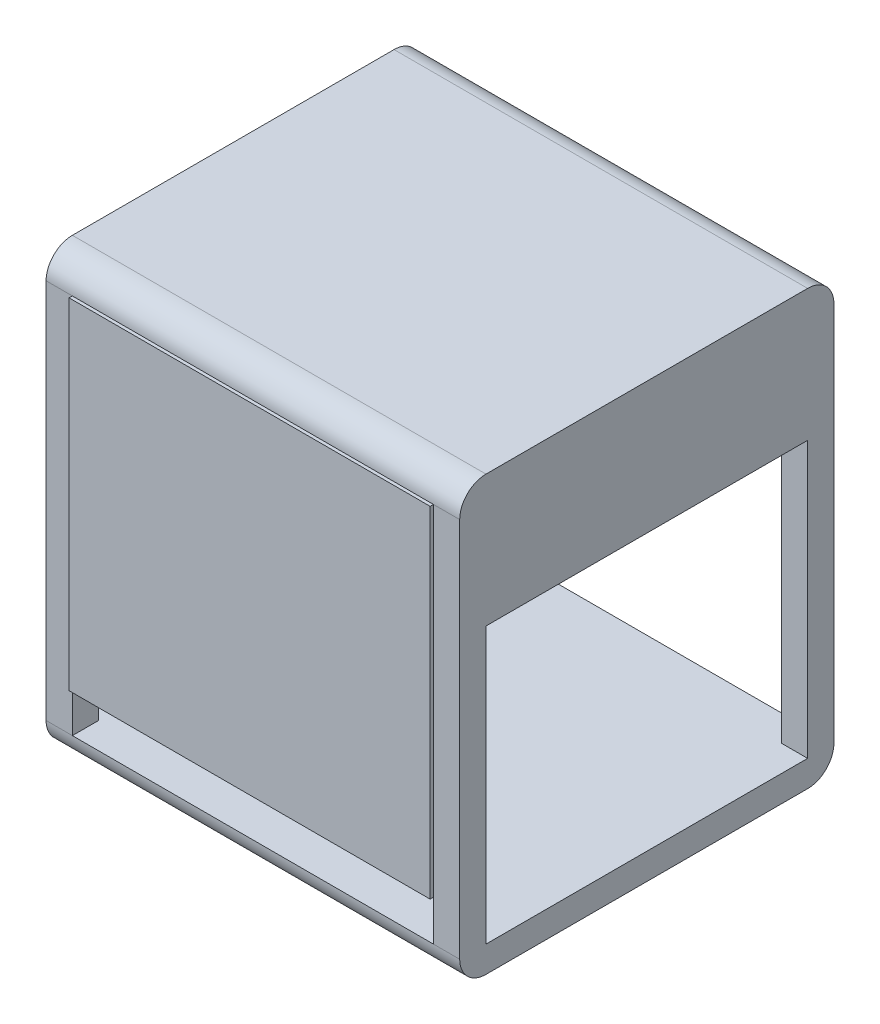
from build123d import *

# Parameters (mm, degrees)
SKETCH1_W                = 630
SKETCH1_H                = 570
BOSS_EXTRUDE1_DEPTH      = 660
FILLET1_R                = 40
CUT_EXTRUDE1_DEPTH       = 660
CUT_EXTRUDE1_DEPTH_BACK  = 5000
SKETCH3_W                = 550
SKETCH3_H                = 580
CUT_EXTRUDE2_DEPTH       = 5000
CUT_EXTRUDE2_DEPTH_BACK  = 5000
SKETCH4_W                = 490
SKETCH4_H                = 419.595995266
SKETCH5_W                = 601.346764223
SKETCH5_H                = 47.577370451
BOSS_EXTRUDE2_DEPTH      = 100
BOSS_EXTRUDE3_DEPTH      = 50
BOSS_EXTRUDE3_DEPTH_BACK = 10
SKETCH6_W                = 78.570394343
SKETCH6_H                = 303.095065724
SKETCH7_R                = 11.248698276
BOSS_EXTRUDE4_DEPTH      = 50
BOSS_EXTRUDE4_TAPER      = 8
SKETCH8_W                = 550
SKETCH8_H                = 518.195144688
BOSS_EXTRUDE5_DEPTH      = 5


with BuildPart() as part:
    # Sketch1 → Boss-Extrude1 (new body)
    with BuildSketch(Plane(origin=(0, 0, 0), x_dir=(1, 0, 0), z_dir=(0, 1, 0))):
        with Locations((315, 285)):
            Rectangle(SKETCH1_W, SKETCH1_H)
    extrude(amount=BOSS_EXTRUDE1_DEPTH)

    # Fillet1
    fillet1_edges = [part.edges().sort_by_distance(p)[0] for p in [
        (315, 0, -570),
        (315, 660, -570),
        (315, 0, 0),
        (315, 660, 0),
    ]]
    fillet(fillet1_edges, radius=FILLET1_R)

    # Sketch3 → Cut-Extrude1 (cut, two sides: drawn at the far end of the back side and taken through both)
    with BuildSketch(Plane.XY.offset(-CUT_EXTRUDE1_DEPTH_BACK)):
        with Locations((315, 330)):
            Rectangle(SKETCH3_W, SKETCH3_H)
    extrude(amount=CUT_EXTRUDE1_DEPTH + CUT_EXTRUDE1_DEPTH_BACK, mode=Mode.SUBTRACT)

    # Sketch4 → Cut-Extrude2 (cut, two sides: drawn at the far end of the back side and taken through both)
    with BuildSketch(Plane(origin=(630, 0, 0), x_dir=(0, 0, -1), z_dir=(1, 0, 0)).offset(-CUT_EXTRUDE2_DEPTH_BACK)):
        with Locations((285, 249.797997633)):
            Rectangle(SKETCH4_W, SKETCH4_H)
    extrude(amount=CUT_EXTRUDE2_DEPTH + CUT_EXTRUDE2_DEPTH_BACK, mode=Mode.SUBTRACT)

    # Sketch5 → Boss-Extrude2 (add)
    with BuildSketch(Plane(origin=(0, 620, 0), x_dir=(-1, 0, 0), z_dir=(0, -1, 0))):
        with Locations((-312.270150876, 350.516378981)):
            Rectangle(SKETCH5_W, SKETCH5_H)
    extrude(amount=BOSS_EXTRUDE2_DEPTH)

    # Sketch6 → Boss-Extrude3 (add, two sides: drawn at the far end of the back side and taken through both)
    with BuildSketch(Plane.XY.offset(-326.727693756).offset(-BOSS_EXTRUDE3_DEPTH_BACK)):
        with Locations((142.054821649, 468.452467138)):
            Rectangle(SKETCH6_W, SKETCH6_H)
    extrude(amount=BOSS_EXTRUDE3_DEPTH + BOSS_EXTRUDE3_DEPTH_BACK)

    # Sketch7 → Boss-Extrude4 (add)
    with BuildSketch(Plane(origin=(0, 316.904934276, 0), x_dir=(-1, 0, 0), z_dir=(0, -1, 0))):
        with Locations((-141.069612942, 317.368211044)):
            Circle(SKETCH7_R)
    extrude(amount=BOSS_EXTRUDE4_DEPTH, taper=BOSS_EXTRUDE4_TAPER)


with BuildPart() as body_2:
    # Sketch8 → Boss-Extrude5 (new body)
    with BuildSketch(Plane.XY):
        with Locations((315, 360.902427656)):
            Rectangle(SKETCH8_W, SKETCH8_H)
    extrude(amount=BOSS_EXTRUDE5_DEPTH)


solid = Compound([part.part, body_2.part])
